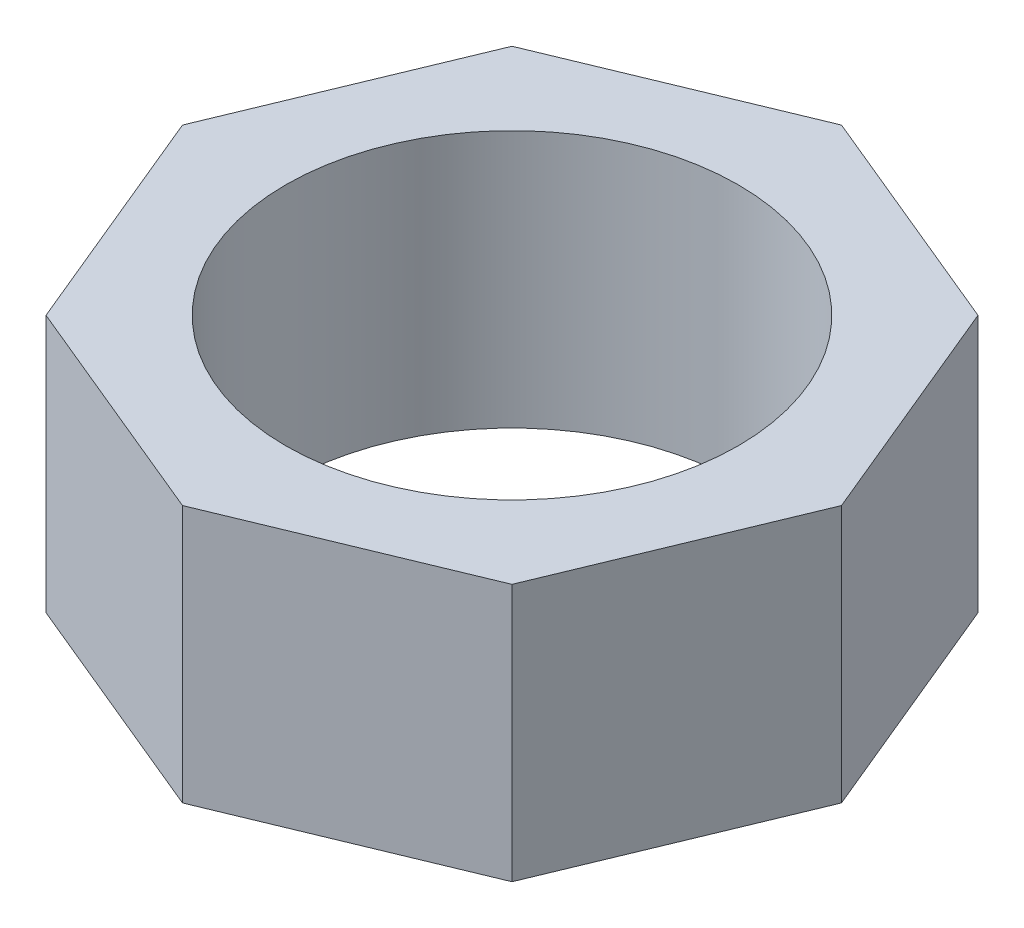
from build123d import *

# Parameters (mm, degrees)
SKETCH1_R           = 42.15
BOSS_EXTRUDE2_DEPTH = 48


with BuildPart() as part:
    # Sketch1 → Boss-Extrude2 (new body)
    with BuildSketch(Plane(origin=(0, 0, 0), x_dir=(1, 0, 0), z_dir=(0, 1, 0))):
        Polygon((0, -57.902642122), (43.422338028, -39.916520801), (61.408459349, 3.505817227), (43.422338028, 46.928155255), (0, 64.914276577), (-43.422338028, 46.928155255), (-61.408459349, 3.505817227), (-43.422338028, -39.916520801), align=None)
        with Locations((0, 3.505817227)):
            Circle(SKETCH1_R, mode=Mode.SUBTRACT)
    extrude(amount=BOSS_EXTRUDE2_DEPTH)


solid = part.part
